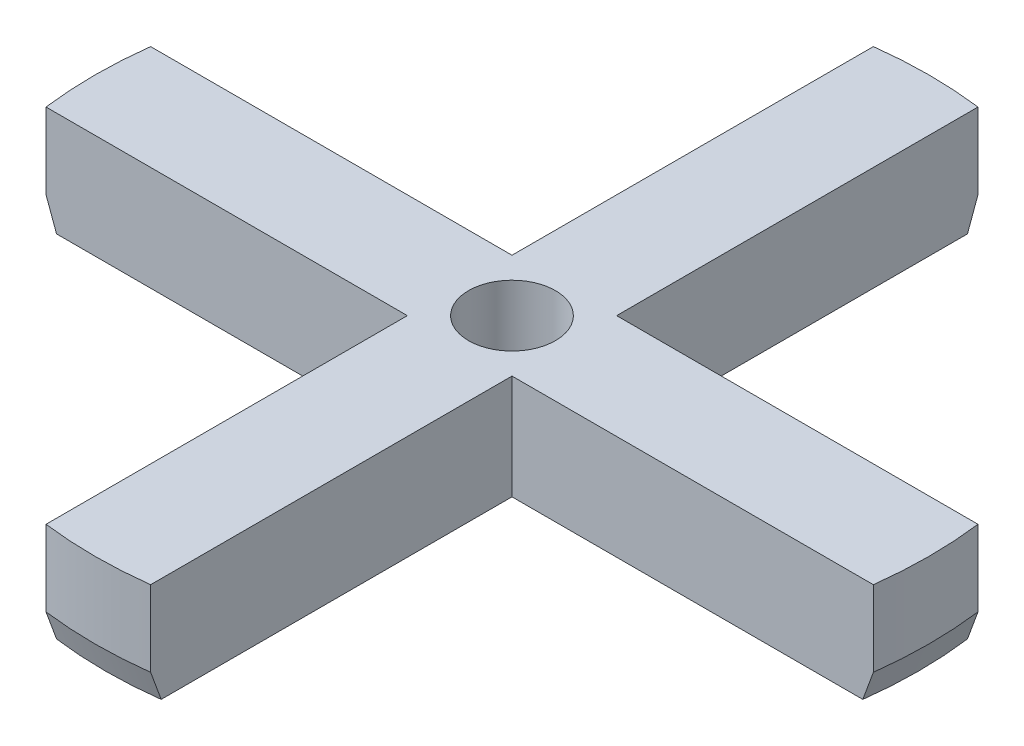
from build123d import *

# Parameters (mm, degrees)
SKETCH1_R           = 4.15
BOSS_EXTRUDE1_DEPTH = 10
CHAMFER1_SIZE       = 1
CHAMFER1_SIZE2      = 2.747477419


with BuildPart() as part:
    # Sketch1 → Boss-Extrude1 (new body)
    with BuildSketch(Plane(origin=(0, 0, 0), x_dir=(1, 0, 0), z_dir=(0, 1, 0))):
        with BuildLine():
            Line((-39.53507936, 5), (-5, 5))
            Line((-5, 5), (-5, 39.53507936))
            ThreePointArc((-5, 39.53507936), (0, 39.85), (5, 39.53507936))
            Line((5, 39.53507936), (5, 5))
            Line((5, 5), (39.53507936, 5))
            ThreePointArc((39.53507936, 5), (39.85, 0), (39.53507936, -5))
            Line((39.53507936, -5), (5, -5))
            Line((5, -5), (5, -39.53507936))
            ThreePointArc((5, -39.53507936), (0, -39.85), (-5, -39.53507936))
            Line((-5, -39.53507936), (-5, -5))
            Line((-5, -5), (-39.53507936, -5))
            ThreePointArc((-39.53507936, -5), (-39.85, 0), (-39.53507936, 5))
        make_face()
        with Locations(Location((0, 0, 0), (0, 0, 270))):  # turned: the seam where the file's is
            Circle(SKETCH1_R, mode=Mode.SUBTRACT)
    extrude(amount=BOSS_EXTRUDE1_DEPTH)

    # Chamfer1
    chamfer1_edges = [part.edges().sort_by_distance(p)[0] for p in [
        (39.85, 0, 0),
        (0, 0, 39.85),
        (-39.85, 0, 0),
        (0, 0, -39.85),
    ]]
    chamfer1_side = [part.faces().sort_by_distance(p)[0] for p in [
        (-22.26753968, 0, -3.872871791),
    ]]
    chamfer(chamfer1_edges, length=CHAMFER1_SIZE, length2=CHAMFER1_SIZE2, reference=chamfer1_side[0])


solid = part.part
